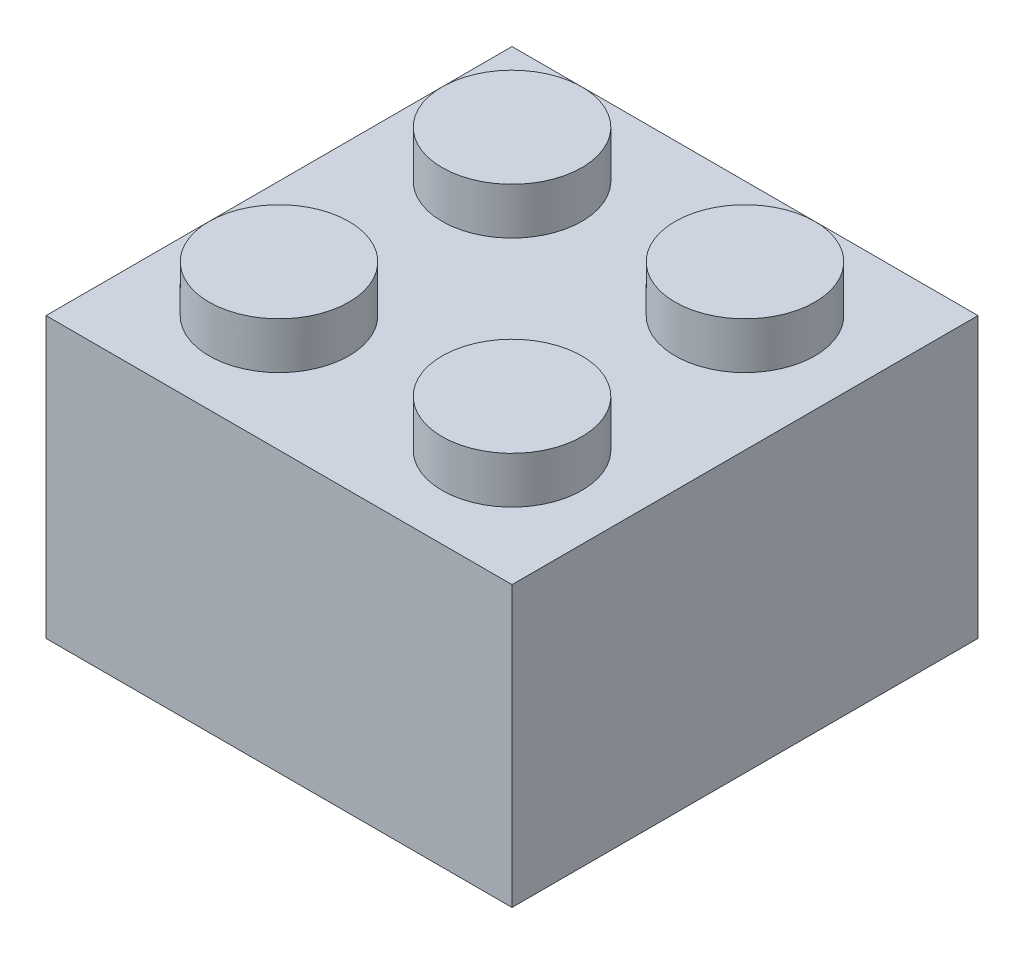
from build123d import *

# Parameters (mm, degrees)
SKETCH1_W           = 10
SKETCH1_H           = 10
SKETCH1_W_2         = 8
SKETCH1_H_2         = 8
BOSS_EXTRUDE1_DEPTH = 6
BOSS_EXTRUDE2_REACH = 11
SKETCH2_W           = 8
SKETCH2_H           = 1
SKETCH3_R           = 1.5
BOSS_EXTRUDE3_DEPTH = 1
BOSS_EXTRUDE4_DEPTH = 5
SKETCH5_R           = 0.75
CUT_EXTRUDE2_DEPTH  = 1


with BuildPart() as part:
    # Sketch1 → Boss-Extrude1 (new body)
    with BuildSketch(Plane(origin=(0, 0, 0), x_dir=(1, 0, 0), z_dir=(0, 1, 0))):
        with Locations((5, 5)):
            Rectangle(SKETCH1_W, SKETCH1_H)
        with Locations((5, 5)):
            Rectangle(SKETCH1_W_2, SKETCH1_H_2, mode=Mode.SUBTRACT)
    extrude(amount=BOSS_EXTRUDE1_DEPTH)

    # Sketch2 → Boss-Extrude2 (add, up to next)
    with BuildSketch(Plane.XY.offset(-9), mode=Mode.PRIVATE) as boss_extrude2_sk1:
        with Locations((5, 5.5)):
            Rectangle(SKETCH2_W, SKETCH2_H)
    boss_extrude2_tool1 = extrude(boss_extrude2_sk1.sketch, amount=BOSS_EXTRUDE2_REACH, mode=Mode.PRIVATE) - part.part
    add(boss_extrude2_tool1.solids().sort_by_distance((5, 5.5, -9))[0])

    # Sketch3 → Boss-Extrude3 (add)
    with BuildSketch(Plane(origin=(0, 6, 0), x_dir=(1, 0, 0), z_dir=(0, 1, 0))):
        with Locations((2.5, 2.5)):
            Circle(SKETCH3_R)
        with Locations((7.5, 2.5)):
            Circle(SKETCH3_R)
        with Locations((7.5, 7.5)):
            Circle(SKETCH3_R)
        with Locations((2.5, 7.5)):
            Circle(SKETCH3_R)
    extrude(amount=BOSS_EXTRUDE3_DEPTH)

    # Sketch4 → Boss-Extrude4 (add)
    with BuildSketch(Plane(origin=(0, 5, 0), x_dir=(-1, 0, 0), z_dir=(0, -1, 0))):
        with BuildLine():
            Line((-3.5, 5), (-2.964466094, 5))
            ThreePointArc((-2.964466094, 5), (-3.560660172, 6.439339828), (-5, 7.035533906))
            Line((-5, 7.035533906), (-5, 6.5))
            ThreePointArc((-5, 6.5), (-3.939339828, 6.060660172), (-3.5, 5))
        make_face()
        with BuildLine():
            Line((-5, 6.5), (-5, 7.035533906))
            ThreePointArc((-5, 7.035533906), (-5.778965109, 6.88058811), (-6.43933984, 6.439339817))
            ThreePointArc((-6.43933984, 6.439339817), (-6.880588116, 5.778965094), (-7.035533906, 5))
            Line((-7.035533906, 5), (-6.5, 5))
            ThreePointArc((-6.5, 5), (-6.060660172, 6.060660172), (-5, 6.5))
        make_face()
        with BuildLine():
            ThreePointArc((-5, 2.964466094), (-3.560660172, 3.560660172), (-2.964466094, 5))
            Line((-2.964466094, 5), (-3.5, 5))
            ThreePointArc((-3.5, 5), (-3.939339828, 3.939339828), (-5, 3.5))
            Line((-5, 3.5), (-5, 2.964466094))
        make_face()
        with BuildLine():
            ThreePointArc((-7.035533906, 5), (-6.439339828, 3.560660172), (-5, 2.964466094))
            Line((-5, 2.964466094), (-5, 3.5))
            ThreePointArc((-5, 3.5), (-6.060660172, 3.939339828), (-6.5, 5))
            Line((-6.5, 5), (-7.035533906, 5))
        make_face()
    extrude(amount=BOSS_EXTRUDE4_DEPTH)

    # Sketch5 → Cut-Extrude2 (cut)
    with BuildSketch(Plane(origin=(0, 5, 0), x_dir=(-1, 0, 0), z_dir=(0, -1, 0))):
        with BuildLine():
            ThreePointArc((-7.5, 6.75), (-6.969669914, 6.969669914), (-6.75, 7.5))
            Line((-6.75, 7.5), (-7.5, 7.5))
            Line((-7.5, 7.5), (-7.5, 6.75))
        make_face()
        with BuildLine():
            Line((-7.5, 7.5), (-6.75, 7.5))
            ThreePointArc((-6.75, 7.5), (-8.030330086, 8.030330086), (-7.5, 6.75))
            Line((-7.5, 6.75), (-7.5, 7.5))
        make_face()
        with Locations((-2.5, 7.5)):
            Circle(SKETCH5_R)
        with Locations((-2.5, 2.5)):
            Circle(SKETCH5_R)
        with Locations((-7.5, 2.5)):
            Circle(SKETCH5_R)
    extrude(amount=-CUT_EXTRUDE2_DEPTH, mode=Mode.SUBTRACT)


solid = part.part
